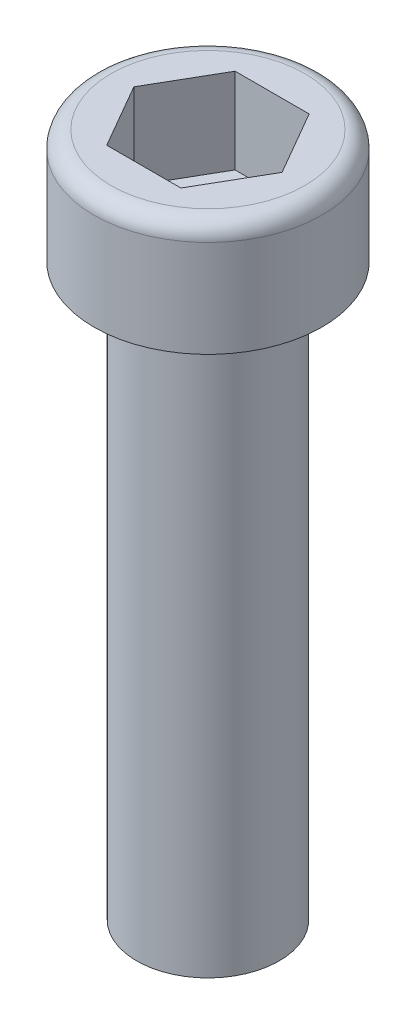
from build123d import *

# Parameters (mm, degrees)
SKETCH1_R           = 2
BOSS_EXTRUDE1_DEPTH = 2
SKETCH2_R           = 1.25
BOSS_EXTRUDE2_DEPTH = 10
FILLET1_R           = 0.3
CUT_EXTRUDE1_DEPTH  = 1.5


with BuildPart() as part:
    # Sketch1 → Boss-Extrude1 (new body)
    with BuildSketch(Plane(origin=(0, 0, 0), x_dir=(1, 0, 0), z_dir=(0, 1, 0))):
        Circle(SKETCH1_R)
    extrude(amount=BOSS_EXTRUDE1_DEPTH)

    # Sketch2 → Boss-Extrude2 (add)
    with BuildSketch(Plane.XZ):
        Circle(SKETCH2_R)
    extrude(amount=BOSS_EXTRUDE2_DEPTH)

    # Fillet1
    fillet1_edges = [part.edges().sort_by_distance(p)[0] for p in [
        (-2, 2, 0),
    ]]
    fillet(fillet1_edges, radius=FILLET1_R)

    # Sketch4 → Cut-Extrude1 (cut)
    with BuildSketch(Plane(origin=(0, 2, 0), x_dir=(1, 0, 0), z_dir=(0, 1, 0))):
        Polygon((1.299038106, 0), (0.649519053, 1.125), (-0.649519053, 1.125), (-1.299038106, 0), (-0.649519053, -1.125), (0.649519053, -1.125), align=None)
    extrude(amount=-CUT_EXTRUDE1_DEPTH, mode=Mode.SUBTRACT)


solid = part.part
